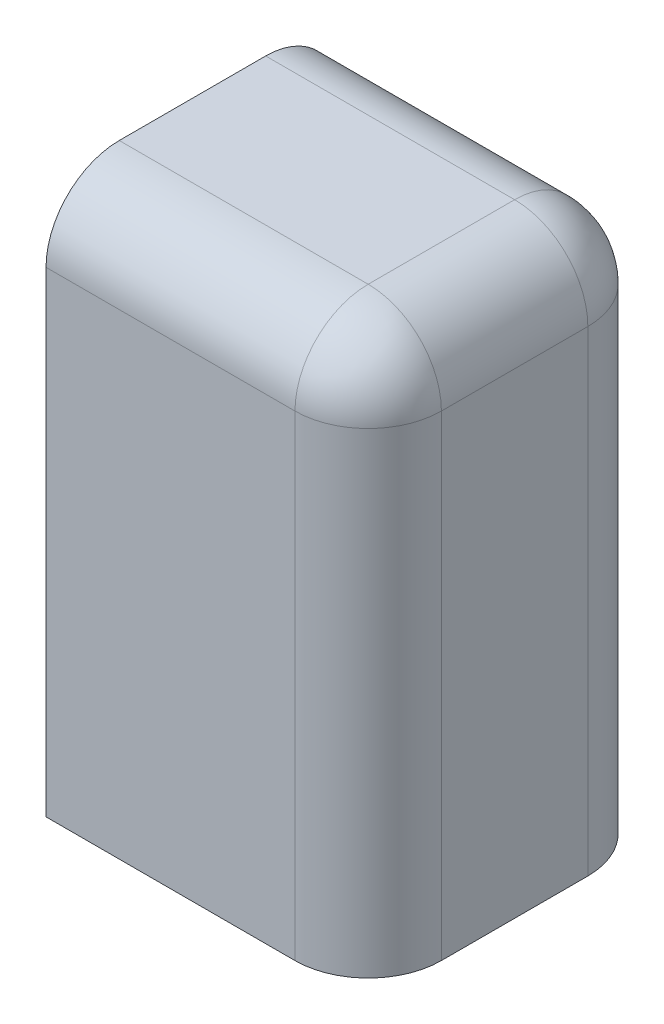
from build123d import *

# Parameters (mm, degrees)
SKETCH1_W           = 4.4
SKETCH1_H           = 4
BOSS_EXTRUDE1_DEPTH = 7.5
SKETCH2_R           = 0.925
CUT_EXTRUDE1_DEPTH  = 5.5
FILLET1_R           = 1


with BuildPart() as part:
    # Sketch1 → Boss-Extrude1 (new body)
    with BuildSketch(Plane(origin=(0, 0, 0), x_dir=(1, 0, 0), z_dir=(0, 1, 0))):
        with Locations((2.2, 2)):
            Rectangle(SKETCH1_W, SKETCH1_H)
    extrude(amount=BOSS_EXTRUDE1_DEPTH)

    # Sketch2 → Cut-Extrude1 (cut)
    with BuildSketch(Plane.XZ):
        with Locations((2.4, -2)):
            Circle(SKETCH2_R)
    extrude(amount=-CUT_EXTRUDE1_DEPTH, mode=Mode.SUBTRACT)

    # Fillet1
    fillet1_edges = [part.edges().sort_by_distance(p)[0] for p in [
        (4.4, 7.5, -2),
        (2.2, 7.5, -4),
        (4.4, 3.75, -4),
        (4.4, 3.75, 0),
        (2.2, 7.5, 0),
    ]]
    fillet(fillet1_edges, radius=FILLET1_R)


solid = part.part
